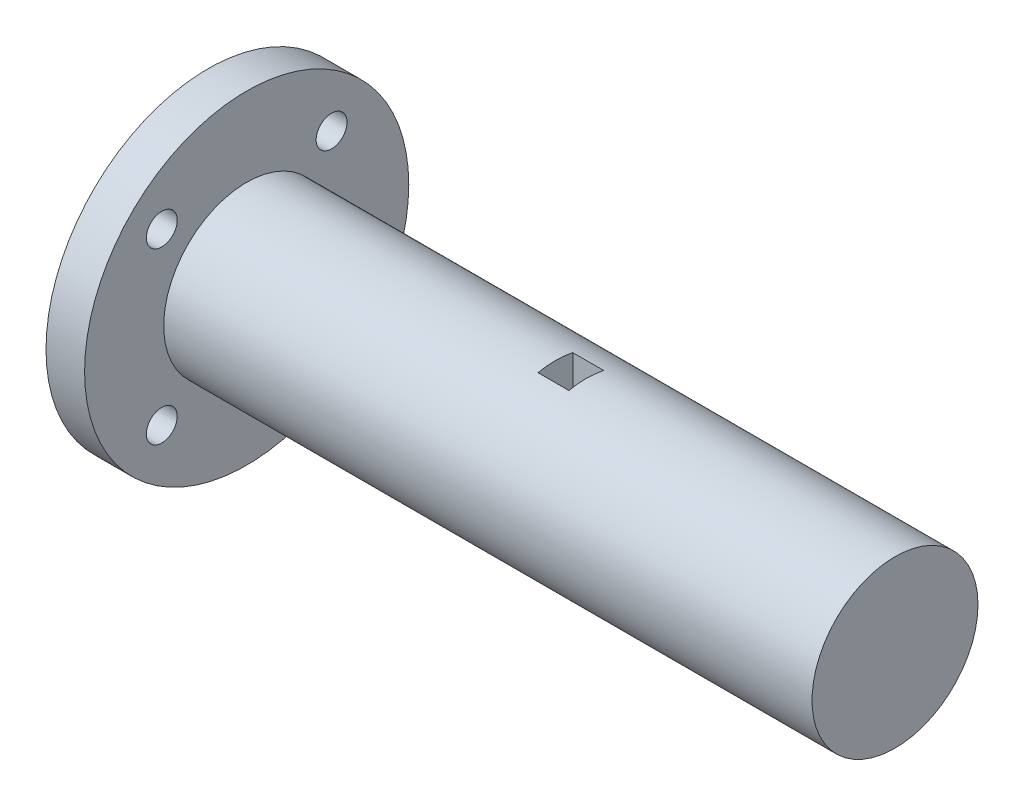
from build123d import *

# Parameters (mm, degrees)
SKETCH1_R           = 10.75
BOSS_EXTRUDE1_DEPTH = 40
SKETCH4_R           = 21
SKETCH4_R_2         = 2
BOSS_EXTRUDE3_DEPTH = 5
BOSS_EXTRUDE5_DEPTH = 4
SKETCH7_R           = 10.75
BOSS_EXTRUDE6_DEPTH = 40


with BuildPart() as part:
    # Sketch1 → Boss-Extrude1 (new body)
    with BuildSketch(Plane(origin=(0, 0, 0), x_dir=(0, 0, -1), z_dir=(1, 0, 0))):
        Circle(SKETCH1_R)
    extrude(amount=BOSS_EXTRUDE1_DEPTH)

    # Sketch4 → Boss-Extrude3 (add)
    with BuildSketch(Plane.ZY):
        Circle(SKETCH4_R)
        with Locations((-11, 11)):
            Circle(SKETCH4_R_2, mode=Mode.SUBTRACT)
        with Locations((11, 11)):
            Circle(SKETCH4_R_2, mode=Mode.SUBTRACT)
        with Locations((11, -11)):
            Circle(SKETCH4_R_2, mode=Mode.SUBTRACT)
        with Locations((-11, -11)):
            Circle(SKETCH4_R_2, mode=Mode.SUBTRACT)
    extrude(amount=BOSS_EXTRUDE3_DEPTH)

    # Sketch6 → Boss-Extrude5 (add)
    with BuildSketch(Plane(origin=(40, 0, 0), x_dir=(0, 0, -1), z_dir=(1, 0, 0))):
        with BuildLine():
            Line((-2.25, 6.511898021), (2.25, 6.511898021))
            Line((2.25, 6.511898021), (2.25, 10.511898021))
            ThreePointArc((2.25, 10.511898021), (0, -10.75), (-2.25, 10.511898021))
            Line((-2.25, 10.511898021), (-2.25, 6.511898021))
        make_face()
    extrude(amount=BOSS_EXTRUDE5_DEPTH)

    # Sketch7 → Boss-Extrude6 (add)
    with BuildSketch(Plane(origin=(44, 0, 0), x_dir=(0, 0, -1), z_dir=(1, 0, 0))):
        Circle(SKETCH7_R)
    extrude(amount=BOSS_EXTRUDE6_DEPTH)


solid = part.part
